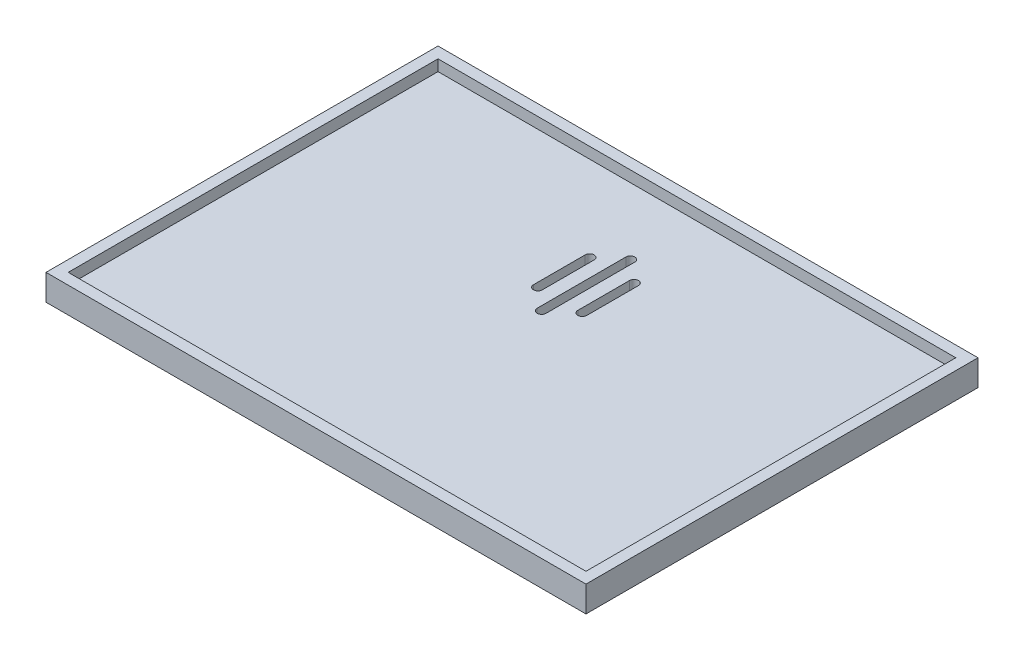
from build123d import *

# Parameters (mm, degrees)
SKETCH1_W           = 73
SKETCH1_H           = 53
BOSS_EXTRUDE1_DEPTH = 2
SKETCH2_W           = 73
SKETCH2_H           = 53
SKETCH2_W_2         = 70
SKETCH2_H_2         = 50
BOSS_EXTRUDE2_DEPTH = 1.5
CUT_EXTRUDE1_DEPTH  = 4.5


with BuildPart() as part:
    # Sketch1 → Boss-Extrude1 (new body)
    with BuildSketch(Plane(origin=(0, 0, 0), x_dir=(1, 0, 0), z_dir=(0, 1, 0))):
        Rectangle(SKETCH1_W, SKETCH1_H)
    extrude(amount=BOSS_EXTRUDE1_DEPTH)

    # Sketch2 → Boss-Extrude2 (add)
    with BuildSketch(Plane(origin=(0, 2, 0), x_dir=(1, 0, 0), z_dir=(0, 1, 0))):
        Rectangle(SKETCH2_W, SKETCH2_H)
        Rectangle(SKETCH2_W_2, SKETCH2_H_2, mode=Mode.SUBTRACT)
    extrude(amount=BOSS_EXTRUDE2_DEPTH)

    # Sketch3 → Cut-Extrude1 (cut, through all)
    with BuildSketch(Plane.XZ):
        with BuildLine():
            Line((0.6, -4), (0.6, -16))
            ThreePointArc((0.6, -16), (0, -16.6), (-0.6, -16))
            Line((-0.6, -16), (-0.6, -4))
            ThreePointArc((-0.6, -4), (0, -3.4), (0.6, -4))
        make_face()
        with BuildLine():
            Line((3.6, -6.5), (3.6, -13.5))
            ThreePointArc((3.6, -13.5), (3, -14.1), (2.4, -13.5))
            Line((2.4, -13.5), (2.4, -6.5))
            ThreePointArc((2.4, -6.5), (3, -5.9), (3.6, -6.5))
        make_face()
        with BuildLine():
            Line((-2.4, -6.5), (-2.4, -13.5))
            ThreePointArc((-2.4, -13.5), (-3, -14.1), (-3.6, -13.5))
            Line((-3.6, -13.5), (-3.6, -6.5))
            ThreePointArc((-3.6, -6.5), (-3, -5.9), (-2.4, -6.5))
        make_face()
    extrude(amount=-CUT_EXTRUDE1_DEPTH, mode=Mode.SUBTRACT)


solid = part.part
